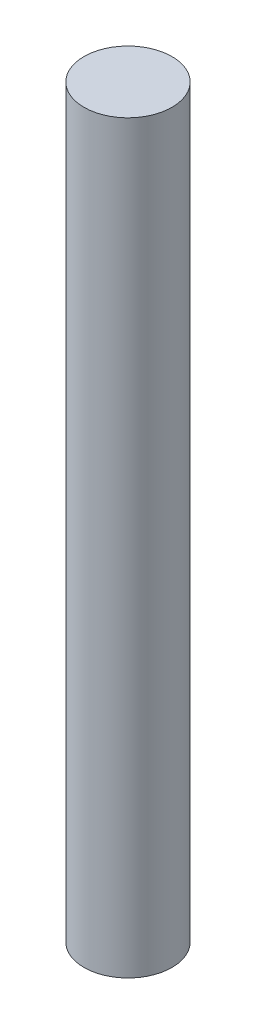
from build123d import *

# Parameters (mm, degrees)
SKETCH1_R           = 0.75
BOSS_EXTRUDE1_DEPTH = 12.7


with BuildPart() as part:
    # Sketch1 → Boss-Extrude1 (new body)
    with BuildSketch(Plane(origin=(0, 0, 0), x_dir=(1, 0, 0), z_dir=(0, 1, 0))):
        Circle(SKETCH1_R)
    extrude(amount=BOSS_EXTRUDE1_DEPTH)


solid = part.part
